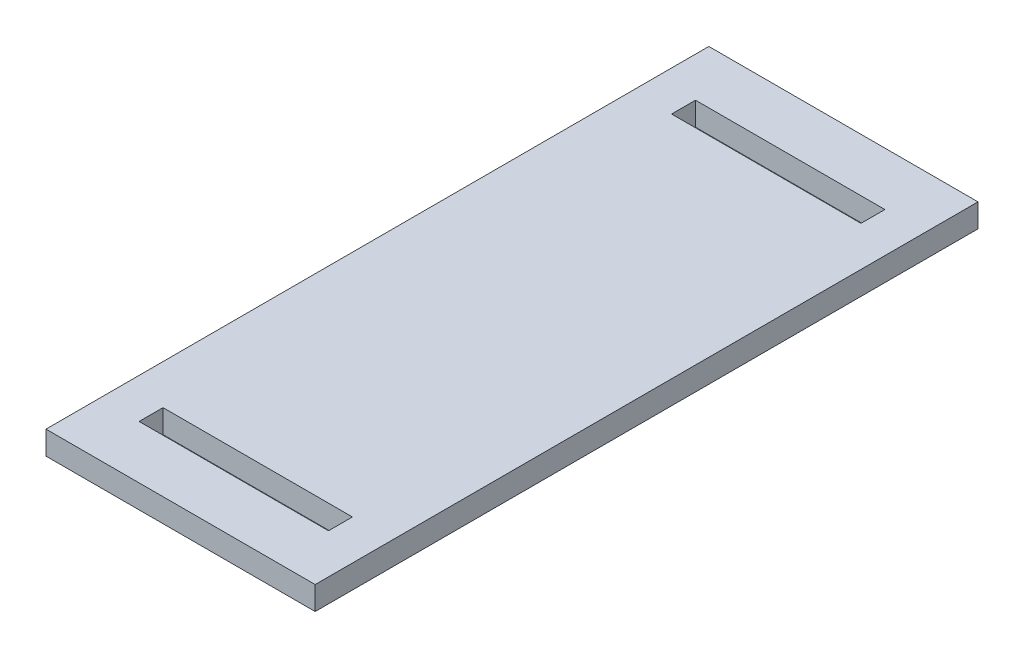
from build123d import *

# Parameters (mm, degrees)
SKETCH1_W           = 64.262
SKETCH1_H           = 158.242
SKETCH1_W_2         = 45.212
SKETCH1_H_2         = 5.715
BOSS_EXTRUDE1_DEPTH = 5.588


with BuildPart() as part:
    # Sketch1 → Boss-Extrude1 (new body)
    with BuildSketch(Plane(origin=(0, 0, 0), x_dir=(1, 0, 0), z_dir=(0, 1, 0))):
        Rectangle(SKETCH1_W, SKETCH1_H)
        with Locations((0, -63.5635)):
            Rectangle(SKETCH1_W_2, SKETCH1_H_2, mode=Mode.SUBTRACT)
        with Locations((0, 63.5635)):
            Rectangle(SKETCH1_W_2, SKETCH1_H_2, mode=Mode.SUBTRACT)
    extrude(amount=BOSS_EXTRUDE1_DEPTH)


solid = part.part
